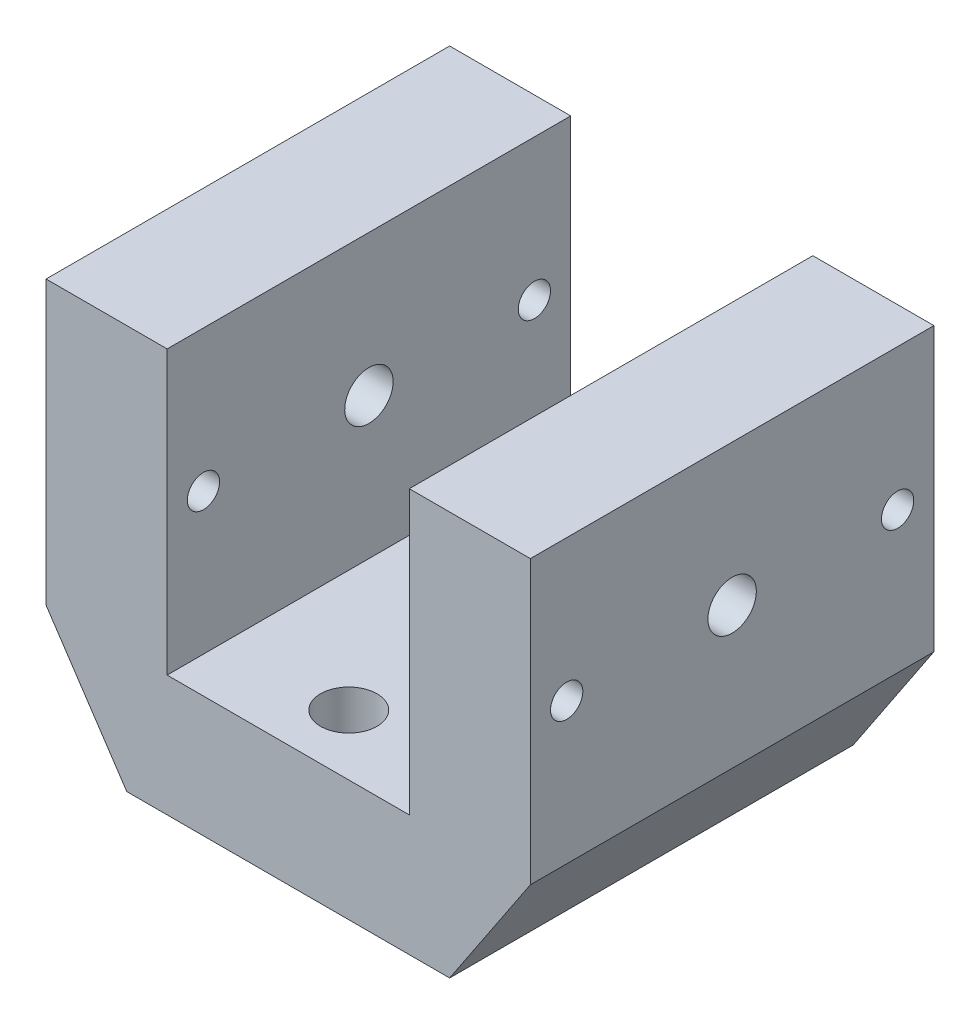
from build123d import *

# Parameters (mm, degrees)
SKETCH1_W               = 120
SKETCH1_H               = 100
BOSS_EXTRUDE1_DEPTH     = 100
SKETCH2_W               = 60
SKETCH2_H               = 70
CUT_EXTRUDE2_DEPTH      = 101
CUT_EXTRUDE2_DEPTH_BACK = 1
SKETCH3_R               = 4
CUT_EXTRUDE3_DEPTH      = 51
CUT_EXTRUDE3_DEPTH_BACK = 51
SKETCH5_R               = 4
CUT_EXTRUDE4_DEPTH      = 61
CUT_EXTRUDE4_DEPTH_BACK = 61
SKETCH6_R               = 6
CUT_EXTRUDE5_DEPTH      = 61
CUT_EXTRUDE5_DEPTH_BACK = 61
CUT_EXTRUDE7_START      = -20
SKETCH7_R               = 7
CUT_EXTRUDE7_DEPTH      = 10


with BuildPart() as part:
    # Sketch1 → Boss-Extrude1 (new body)
    with BuildSketch(Plane.XY):
        Rectangle(SKETCH1_W, SKETCH1_H)
    extrude(amount=BOSS_EXTRUDE1_DEPTH)

    # Sketch2 → Cut-Extrude2 (cut, two sides)
    with BuildSketch(Plane.XY) as cut_extrude2_sk:
        Polygon((-60, -20), (-40, -50), (-60, -50), align=None)
        with Locations((0, 15)):
            Rectangle(SKETCH2_W, SKETCH2_H)
        Polygon((60, -50), (40, -50), (60, -20), align=None)
    extrude(amount=CUT_EXTRUDE2_DEPTH, mode=Mode.SUBTRACT)
    extrude(cut_extrude2_sk.sketch, amount=-CUT_EXTRUDE2_DEPTH_BACK, mode=Mode.SUBTRACT)

    # Sketch3 → Cut-Extrude3 (cut, two sides)
    with BuildSketch(Plane(origin=(0, 0, 0), x_dir=(1, 0, 0), z_dir=(0, 1, 0))) as cut_extrude3_sk:
        with Locations((0, -85)):
            Circle(SKETCH3_R)
        with Locations((0, -15)):
            Circle(SKETCH3_R)
    extrude(amount=CUT_EXTRUDE3_DEPTH, mode=Mode.SUBTRACT)
    extrude(cut_extrude3_sk.sketch, amount=-CUT_EXTRUDE3_DEPTH_BACK, mode=Mode.SUBTRACT)

    # Sketch5 → Cut-Extrude4 (cut, two sides)
    with BuildSketch(Plane(origin=(0, 0, 0), x_dir=(0, 0, -1), z_dir=(1, 0, 0))) as cut_extrude4_sk:
        with Locations((-91, 15)):
            Circle(SKETCH5_R)
        with Locations((-9, 15)):
            Circle(SKETCH5_R)
    extrude(amount=CUT_EXTRUDE4_DEPTH, mode=Mode.SUBTRACT)
    extrude(cut_extrude4_sk.sketch, amount=-CUT_EXTRUDE4_DEPTH_BACK, mode=Mode.SUBTRACT)

    # Sketch6 → Cut-Extrude5 (cut, two sides)
    with BuildSketch(Plane(origin=(0, 0, 0), x_dir=(0, 0, -1), z_dir=(1, 0, 0))) as cut_extrude5_sk:
        with Locations((-50, 15)):
            Circle(SKETCH6_R)
    extrude(amount=CUT_EXTRUDE5_DEPTH, mode=Mode.SUBTRACT)
    extrude(cut_extrude5_sk.sketch, amount=-CUT_EXTRUDE5_DEPTH_BACK, mode=Mode.SUBTRACT)

    # Sketch7 → Cut-Extrude7 (cut)
    with BuildSketch(Plane(origin=(0, 0, 0), x_dir=(1, 0, 0), z_dir=(0, 1, 0)).offset(CUT_EXTRUDE7_START)):
        with Locations((0, -85)):
            Circle(SKETCH7_R)
        with Locations((0, -15)):
            Circle(SKETCH7_R)
    extrude(amount=-CUT_EXTRUDE7_DEPTH, mode=Mode.SUBTRACT)


solid = part.part
